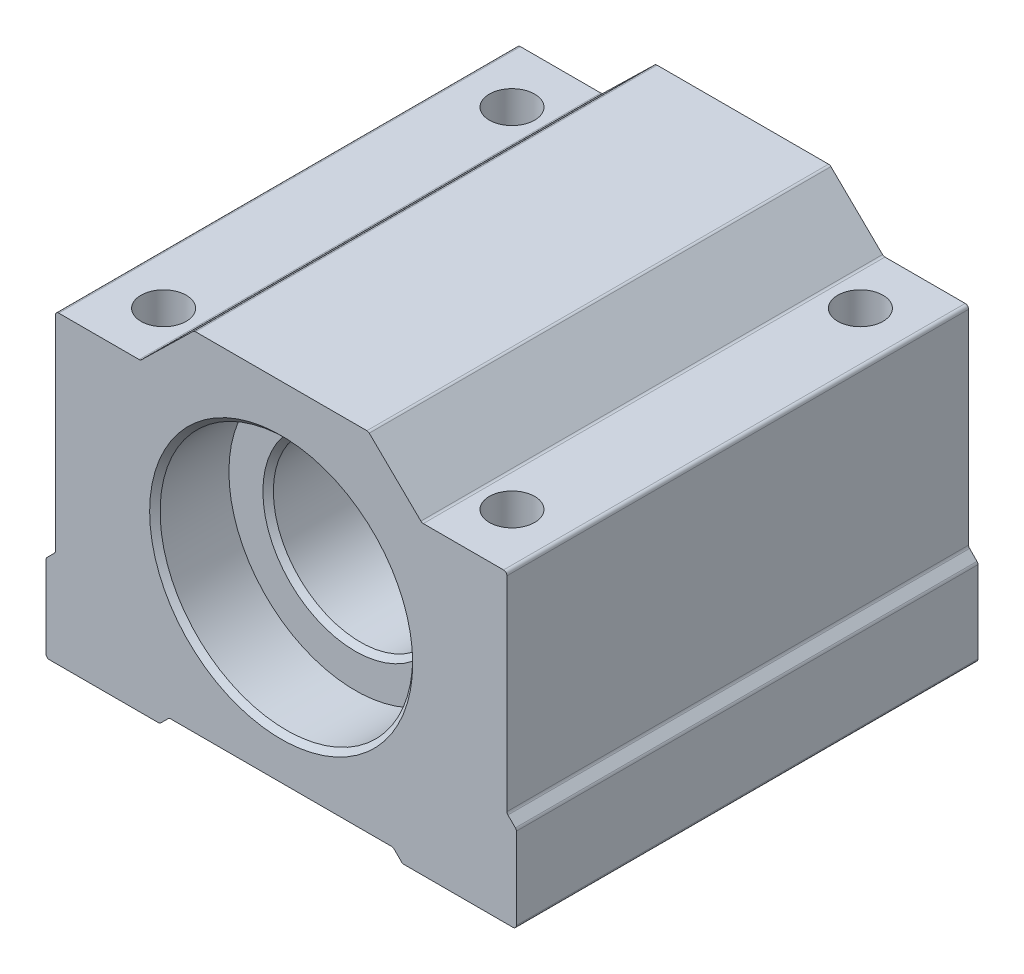
from build123d import *

# Parameters (mm, degrees)
SKETCH2_R               = 10
BOSS_EXTRUDE1_DEPTH     = 26.5
CUT_EXTRUDE1_DEPTH      = 44.029059948
CUT_EXTRUDE1_DEPTH_BACK = 44.029059948
SKETCH3_R               = 2.6
SKETCH12_R              = 14.5
CUT_EXTRUDE9_DEPTH      = 8.5
CHAMFER1_SIZE           = 0.6
FILLET1_R               = 0.39


with BuildPart() as part:
    # Sketch2 → Boss-Extrude1 (new, symmetric)
    with BuildSketch(Plane.XY):
        Polygon((-27, -20.5), (-13.931623932, -20.5), (-12.851623932, -19.42), (12.851623932, -19.42), (13.931623932, -20.5), (27, -20.5), (27, -10.58), (25.92, -9.5), (25.92, 14.5), (16.153846154, 14.5), (10, 20.5), (-10, 20.5), (-16.153846154, 14.5), (-25.92, 14.5), (-25.92, -9.5), (-27, -10.58), align=None)
        Circle(SKETCH2_R, mode=Mode.SUBTRACT)
    extrude(amount=BOSS_EXTRUDE1_DEPTH, both=True)

    # Sketch3 → Cut-Extrude1 (cut, two sides: drawn at the far end of the back side and taken through both)
    with BuildSketch(Plane(origin=(0, 0, 0), x_dir=(1, 0, 0), z_dir=(0, 1, 0)).offset(-CUT_EXTRUDE1_DEPTH_BACK)):
        with Locations((-20, 20)):
            Circle(SKETCH3_R)
        with Locations(Location((20, 20, 0), (0, 0, 90))):
            Circle(SKETCH3_R)
        with Locations(Location((20, -20, 0), (0, 0, 90))):
            Circle(SKETCH3_R)
        with Locations((-20, -20)):
            Circle(SKETCH3_R)
    extrude(amount=CUT_EXTRUDE1_DEPTH + CUT_EXTRUDE1_DEPTH_BACK, mode=Mode.SUBTRACT)

    # Sketch12 → Cut-Extrude9 (cut)
    with BuildSketch(Plane(origin=(0, 0, -26.5), x_dir=(-1, 0, 0), z_dir=(0, 0, -1))):
        Circle(SKETCH12_R)
    cut_extrude9 = extrude(amount=-CUT_EXTRUDE9_DEPTH, mode=Mode.SUBTRACT)

    # Mirror1: Cut-Extrude9 across plane
    add(cut_extrude9.mirror(Plane.XY), mode=Mode.SUBTRACT)

    # Chamfer1
    chamfer1_edges = [part.edges().sort_by_distance(p)[0] for p in [
        (-10, 0, -18),
        (14.5, 0, -26.5),
        (14.5, 0, 26.5),
        (-10, 0, 18),
    ]]
    chamfer(chamfer1_edges, length=CHAMFER1_SIZE)

    # Fillet1
    fillet1_edges = [part.edges().sort_by_distance(p)[0] for p in [
        (-27, -10.58, 0),
        (-25.92, -9.5, 0),
        (-25.92, 14.5, 0),
        (-16.153846154, 14.5, 0),
        (-10, 20.5, 0),
        (10, 20.5, 0),
        (16.153846154, 14.5, 0),
        (25.92, 14.5, 0),
        (25.92, -9.5, 0),
        (27, -10.58, 0),
        (27, -20.5, 0),
        (13.931623932, -20.5, 0),
        (12.851623932, -19.42, 0),
        (-12.851623932, -19.42, 0),
        (-13.931623932, -20.5, 0),
        (-27, -20.5, 0),
    ]]
    fillet(fillet1_edges, radius=FILLET1_R)


solid = part.part
